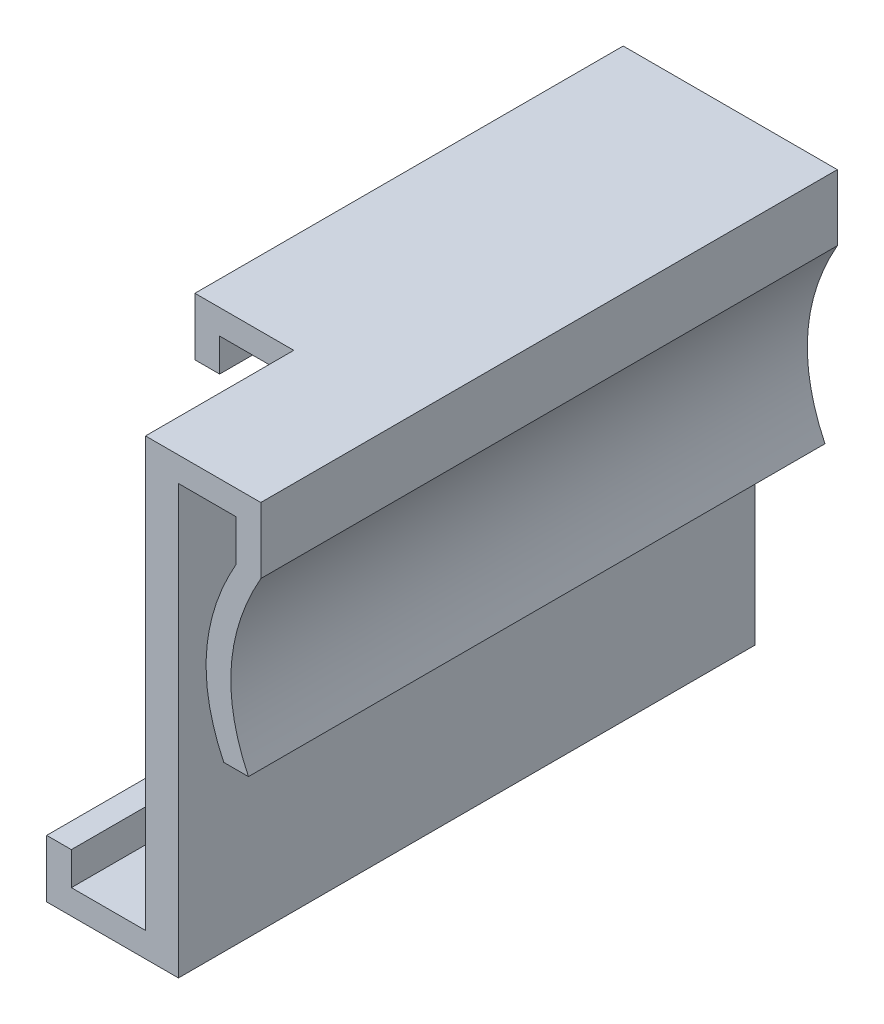
from build123d import *

# Parameters (mm, degrees)
AUFSATZ_LINEAR_AUSTRAGEN1_DEPTH = 35
SCHNITT_LINEAR_AUSTRAGEN1_DEPTH = 9


with BuildPart() as part:
    # Skizze1 → Aufsatz-Linear austragen1 (new body)
    with BuildSketch(Plane.XY):
        with BuildLine():
            add(Edge.make_bspline(
                [(4.5, 9.75), (1.282885482, 4.095735731), (3.75, -1.036897294)],
                knots=[0, 0, 0, 1, 1, 1], degree=2))
            Line((3.75, -1.036897294), (5.25, -1.036897294))
            add(Edge.make_bspline(
                [(6, 9.75), (2.782885482, 4.095735731), (5.25, -1.036897294)],
                knots=[0, 0, 0, 1, 1, 1], degree=2))
            Line((6, 9.75), (6, 13.75))
            Line((6, 13.75), (-7, 13.75))
            Line((-7, 13.75), (-7, 10.25))
            Line((-7, 10.25), (-5.5, 10.25))
            Line((-5.5, 10.25), (-5.5, 12.25))
            Line((-5.5, 12.25), (-1, 12.25))
            Line((-1, 12.25), (-1, -12.25))
            Line((-1, -12.25), (-5.5, -12.25))
            Line((-5.5, -12.25), (-5.5, -10.25))
            Line((-5.5, -10.25), (-7, -10.25))
            Line((-7, -10.25), (-7, -13.75))
            Line((-7, -13.75), (1, -13.75))
            Line((1, -13.75), (1, 12.25))
            Line((1, 12.25), (4.5, 12.25))
            Line((4.5, 12.25), (4.5, 9.75))
        make_face()
    extrude(amount=AUFSATZ_LINEAR_AUSTRAGEN1_DEPTH)

    # Skizze3 → Schnitt-Linear austragen1 (cut)
    with BuildSketch(Plane.XY.offset(35)):
        Polygon((-1, 12.25), (-1, 13.75), (-7, 13.75), (-7, 10.25), (-5.5, 10.25), (-5.5, 12.25), align=None)
    extrude(amount=-SCHNITT_LINEAR_AUSTRAGEN1_DEPTH, mode=Mode.SUBTRACT)


solid = part.part
